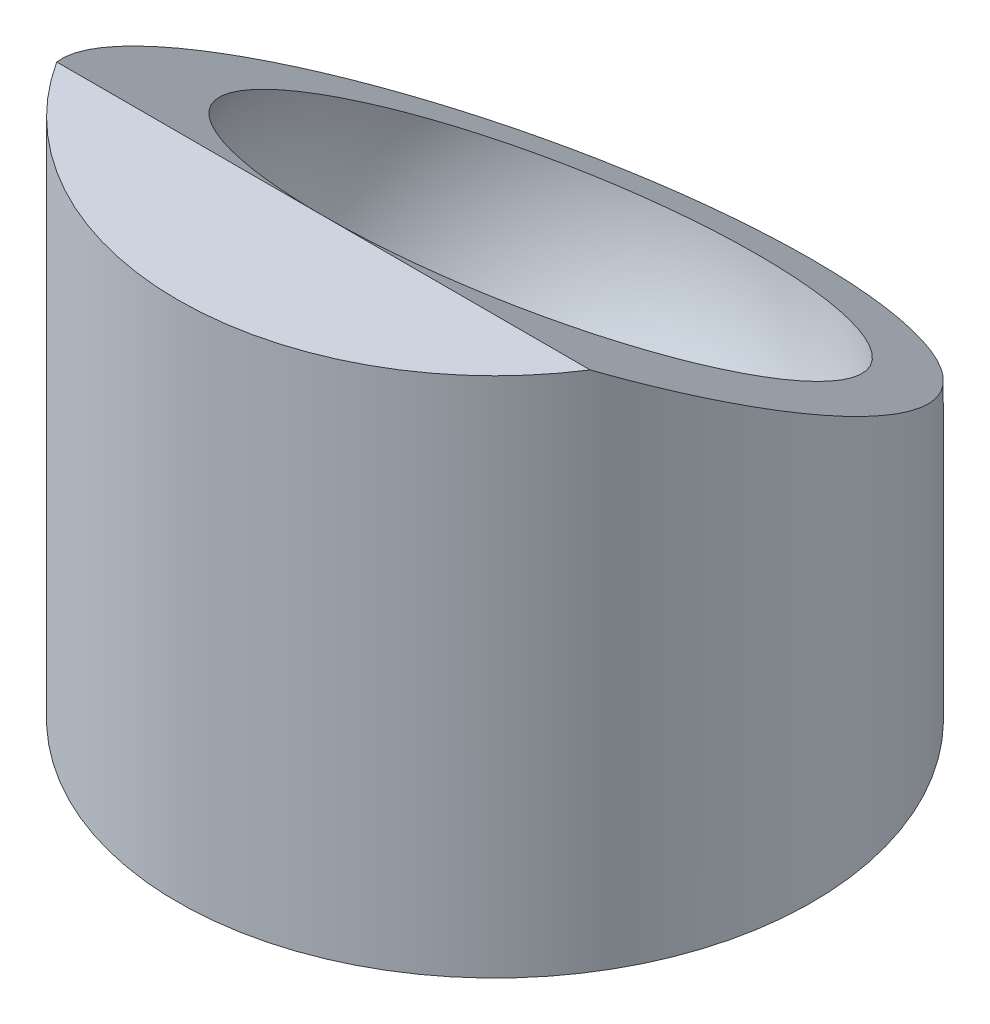
from build123d import *

# Parameters (mm, degrees)
CUT_EXTRUDE1_DEPTH      = 13
CUT_EXTRUDE1_DEPTH_BACK = 13


with BuildPart() as part:
    # Sketch1 → Revolve1 (revolve)
    with BuildSketch(Plane(origin=(0, 0, 0), x_dir=(0, 0, -1), z_dir=(1, 0, 0))):
        with BuildLine():
            Line((-5.05, 8.746856578), (-12, 8.746856578))
            Line((-12, 8.746856578), (-12, -12))
            Line((-12, -12), (0, -12))
            Line((0, -12), (0, -10.1))
            ThreePointArc((0, -10.1), (-9.755850846, -2.614072356), (-5.05, 8.746856578))
        make_face()
    revolve(axis=Axis((0, -12, 0), (0, 1, 0)))

    # Sketch2 → Cut-Extrude1 (cut, two sides)
    with BuildSketch(Plane(origin=(0, 0, 0), x_dir=(0, 0, -1), z_dir=(1, 0, 0))) as cut_extrude1_sk:
        Polygon((-6.492154858, 7.737048876), (9.946558305, -1.753846594), (12, -2.93940171), (12, 8.746856578), (-12, 8.746856578), (-12, 7.737048876), align=None)
    extrude(amount=CUT_EXTRUDE1_DEPTH, mode=Mode.SUBTRACT)
    extrude(cut_extrude1_sk.sketch, amount=-CUT_EXTRUDE1_DEPTH_BACK, mode=Mode.SUBTRACT)


solid = part.part
